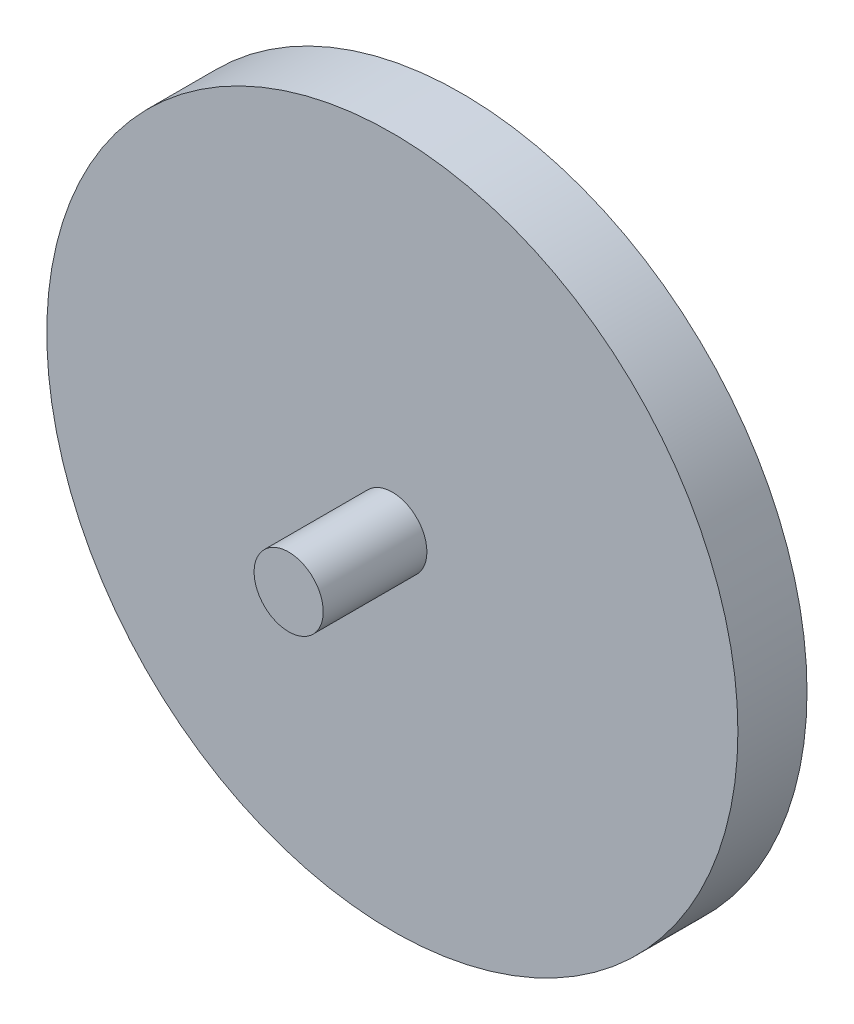
from build123d import *

# Parameters (mm, degrees)
SKETCH_1_R      = 10
EXTRUDE_1_DEPTH = 2
SKETCH_2_R      = 1
EXTRUDE_2_DEPTH = 3


with BuildPart() as part:
    # ｽｹｯﾁ1 → ﾎﾞｽ - 押し出し1 (new body)
    with BuildSketch(Plane.XY):
        with Locations((-8.080131723, 13.964285714)):
            Circle(SKETCH_1_R)
    extrude(amount=EXTRUDE_1_DEPTH)

    # ｽｹｯﾁ2 → ﾎﾞｽ - 押し出し2 (add)
    with BuildSketch(Plane.XY.offset(2)):
        with Locations((-8.080131723, 13.964285714)):
            Circle(SKETCH_2_R)
    extrude(amount=EXTRUDE_2_DEPTH)


solid = part.part
